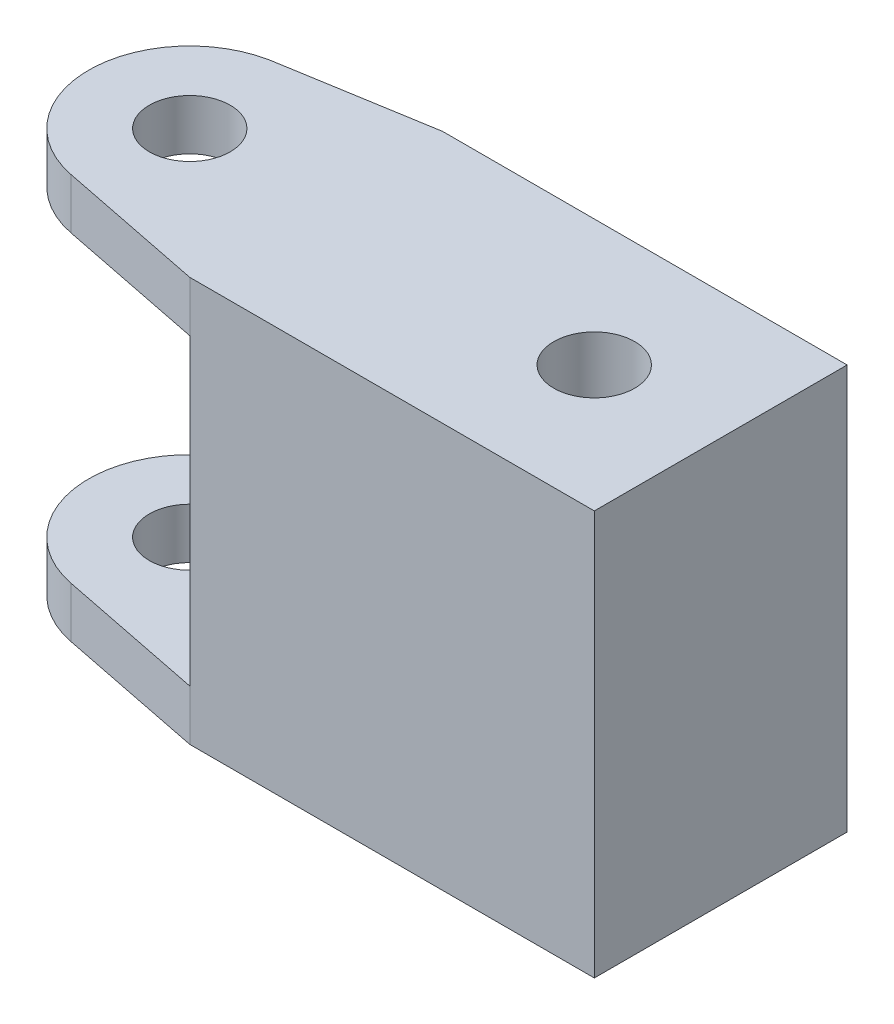
from build123d import *

# Parameters (mm, degrees)
ESQUISSE1_W             = 40
ESQUISSE1_H             = 40
BOSS_EXTRU_1_DEPTH      = 25
ESQUISSE2_R             = 4
ENL_V_MAT_EXTRU_1_DEPTH = 47
ESQUISSE4_R             = 4
BOSS_EXTRU_3_DEPTH      = 5


with BuildPart() as part:
    # Esquisse1 → Boss.-Extru.1 (new body)
    with BuildSketch(Plane.XY):
        Rectangle(ESQUISSE1_W, ESQUISSE1_H)
    extrude(amount=BOSS_EXTRU_1_DEPTH)

    # Esquisse2 → Enlèv. mat.-Extru.1 (cut)
    with BuildSketch(Plane(origin=(0, 20, 0), x_dir=(1, 0, 0), z_dir=(0, 1, 0))):
        with Locations((7.492941833, -12.5)):
            Circle(ESQUISSE2_R)
    extrude(amount=-ENL_V_MAT_EXTRU_1_DEPTH, mode=Mode.SUBTRACT)

    # Esquisse4 → Boss.-Extru.3 (add)
    with BuildSketch(Plane(origin=(0, 20, 0), x_dir=(1, 0, 0), z_dir=(0, 1, 0))):
        with BuildLine():
            Line((-20, -25), (-34.7092612, -22.061014641))
            ThreePointArc((-34.7092612, -22.061014641), (-42.749937628, -12.254840508), (-34.7092612, -2.448666374))
            Line((-34.7092612, -2.448666374), (-20, 0))
            Line((-20, 0), (-20, -25))
        make_face()
        with Locations((-32.749937628, -12.254840508)):
            Circle(ESQUISSE4_R, mode=Mode.SUBTRACT)
    boss_extru_3 = extrude(amount=-BOSS_EXTRU_3_DEPTH)

    # Symétrie2: Boss.-Extru.3 across plane
    add(boss_extru_3.mirror(Plane.ZX))


solid = part.part
